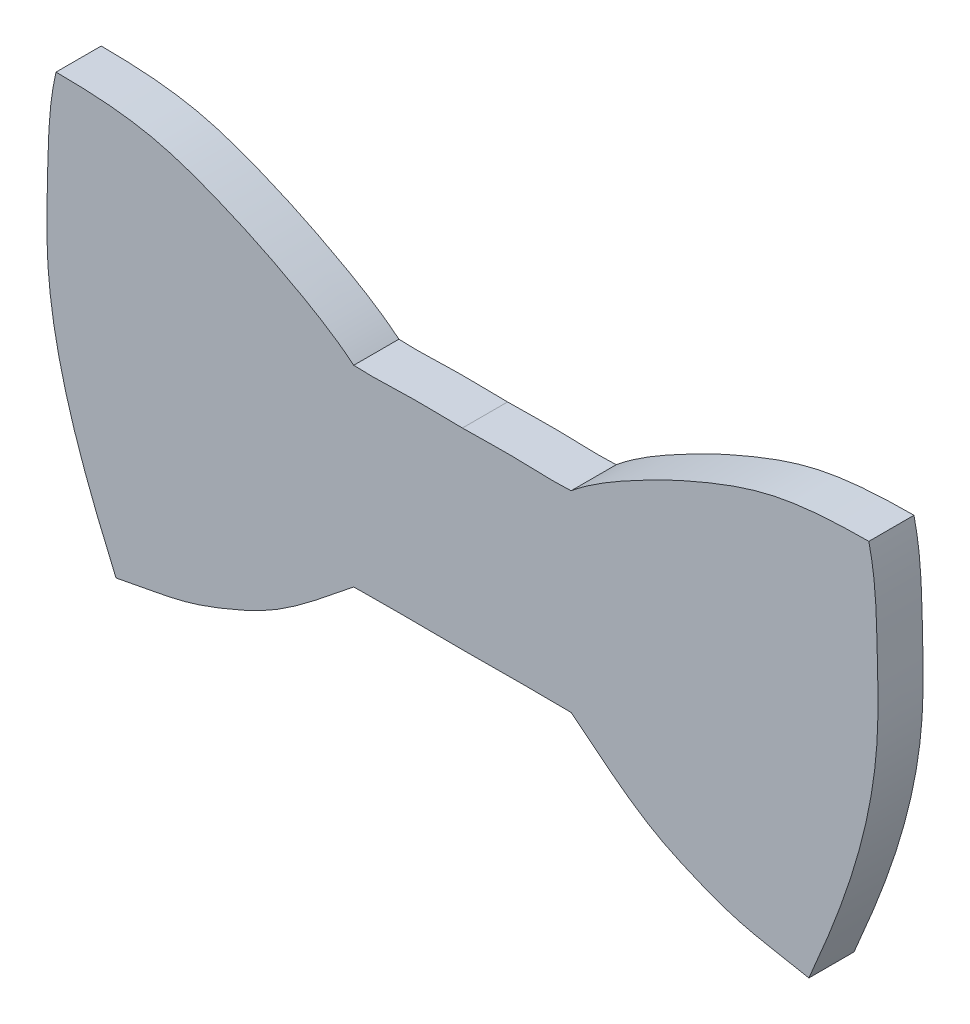
from build123d import *

# Parameters (mm, degrees)
BOSS_EXTRUDE1_DEPTH = 3.175


with BuildPart() as part:
    # Sketch1 → Boss-Extrude1 (new body)
    with BuildSketch(Plane.XY):
        with BuildLine():
            Line((0, 6.239472455), (0, -7.260702217))
            add(Edge.make_bspline(
                [(7.641667961, -7.260702217), (6.173224566, -7.24434781), (3.62582692, -7.226650196), (1.078722065, -7.265547409), (0, -7.260702217)],
                knots=[0, 0, 0, 0, 0.576526412, 1, 1, 1, 1], degree=3))
            add(Edge.make_bspline(
                [(24.360647134, -15.070641791), (22.695069181, -14.712846276), (19.912779569, -14.362267459), (16.373231273, -13.013220857), (12.224668447, -11.126379611), (9.579920278, -8.786238347), (7.641667961, -7.260702217)],
                knots=[0, 0, 0, 0, 0.273274261, 0.444400938, 0.60413243, 1, 1, 1, 1], degree=3))
            add(Edge.make_bspline(
                [(28.575, 13.626690141), (29.102161134, 11.397414075), (29.133975743, 7.620513248), (29.291553814, 2.645522958), (28.813043081, -1.975440767), (27.819941332, -6.030249292), (26.247135541, -10.627034403), (25.111702689, -13.327462029), (24.360647134, -15.070641791)],
                knots=[0, 0, 0, 0, 0.230910751, 0.38373302, 0.505873253, 0.702267707, 0.806837053, 1, 1, 1, 1], degree=3))
            add(Edge.make_bspline(
                [(28.575, 13.626690141), (26.199779562, 13.620610297), (22.186719247, 13.420941971), (17.832136903, 11.80420711), (14.646192699, 10.4307062), (11.456721178, 8.801393468), (8.937335742, 7.311275098), (7.641667961, 6.239472455)],
                knots=[0, 0, 0, 0, 0.316578467, 0.524802591, 0.612692342, 0.777335836, 1, 1, 1, 1], degree=3))
            add(Edge.make_bspline(
                [(7.641667961, 6.239472455), (6.172491471, 6.151300055), (3.626276552, 6.357992663), (1.07879149, 6.223497089), (0, 6.239472455)],
                knots=[0, 0, 0, 0, 0.576548234, 1, 1, 1, 1], degree=3))
        make_face()
    boss_extrude1 = extrude(amount=BOSS_EXTRUDE1_DEPTH)

    # Mirror1: Boss-Extrude1 across plane
    add(boss_extrude1.mirror(Plane(origin=(0, 0, 0), x_dir=(0, 0, 1), z_dir=(1, 0, 0))))


solid = part.part
